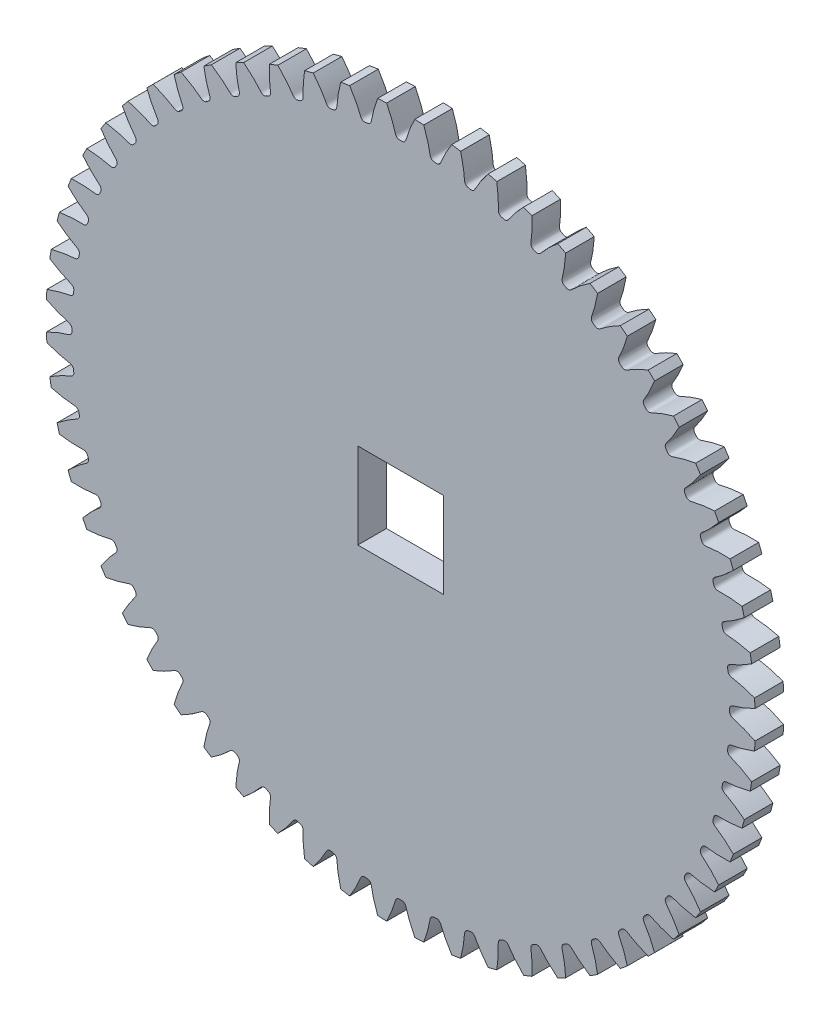
from build123d import *

# Parameters (mm, degrees)
SKETCHREVOLVEENGRANAJE_FINO_12_4_W       = 0.5
SKETCHREVOLVEENGRANAJE_FINO_12_4_H       = 6.2
TOOTHEXTRUDECUTENGRANAJE_FINO_12_4_DEPTH = 0.25
PATTERNENGRANAJE_FINO_12_4_COUNT         = 60
CROQUIS1_W                               = 1.5
CROQUIS1_H                               = 1.5
CORTAR_EXTRUIR1_DEPTH                    = 10


with BuildPart() as part:
    # SketchRevolveEngranaje Fino_12.4 → Engranaje Fino_12.4 (revolve)
    with BuildSketch(Plane(origin=(0, 0, 0), x_dir=(0, 0, -1), z_dir=(1, 0, 0))):
        with Locations((0, 3.1)):
            Rectangle(SKETCHREVOLVEENGRANAJE_FINO_12_4_W, SKETCHREVOLVEENGRANAJE_FINO_12_4_H)
    revolve(axis=Axis((0, 0, 0), (0, 0, -1)))

    # SketchToothEngranaje Fino_12.4 → ToothExtrudeCutEngranaje Fino_12.4 (cut, symmetric)
    with BuildSketch(Plane.XY):
        with BuildLine():
            ThreePointArc((6.204925678, 0.250992683), (6.21, 0), (6.204925678, -0.250992683))
            add(Edge.make_bspline(
                [(6.204925678, -0.250992683), (6.179966329, -0.238222226), (6.1468348, -0.221938109), (6.105502518, -0.202786997), (6.081860826, -0.19215202), (6.058747297, -0.18206364), (6.036171119, -0.172508696), (6.014141246, -0.163473877), (5.992666403, -0.154945749), (5.971755085, -0.146910734), (5.95141554, -0.139355173), (5.931655825, -0.132265126), (5.912483602, -0.125627101), (5.893906846, -0.119425486), (5.87593134, -0.113651649), (5.858569516, -0.108271809), (5.84014338, -0.10285013), (5.826164105, -0.098730913), (5.816332425, -0.096177961), (5.812269746, -0.094977221), (5.808251512, -0.093683063), (5.804262805, -0.092266595), (5.800281537, -0.090708909), (5.796283263, -0.088979434), (5.792239737, -0.087038528), (5.788119777, -0.084832402), (5.783890851, -0.082288663), (5.779523099, -0.079310151), (5.774997526, -0.075768255), (5.770321331, -0.071497671), (5.76555335, -0.066297996), (5.760841668, -0.059952869), (5.756459307, -0.052281293), (5.752833065, -0.04323286), (5.750494435, -0.033314639), (5.749578137, -0.018735376), (5.750293671, 0), (5.749578137, 0.018735376), (5.750494435, 0.033314639), (5.752833065, 0.04323286), (5.756459307, 0.052281293), (5.760841668, 0.059952869), (5.76555335, 0.066297996), (5.770321331, 0.071497671), (5.774997526, 0.075768255), (5.779523099, 0.079310151), (5.783890851, 0.082288663), (5.788119777, 0.084832402), (5.792239737, 0.087038528), (5.796283263, 0.088979434), (5.800281537, 0.090708909), (5.804262805, 0.092266595), (5.808251512, 0.093683063), (5.812269746, 0.094977221), (5.816332425, 0.096177961), (5.826164105, 0.098730913), (5.84014338, 0.10285013), (5.858569516, 0.108271809), (5.87593134, 0.113651649), (5.893906846, 0.119425486), (5.912483602, 0.125627101), (5.931655825, 0.132265126), (5.95141554, 0.139355173), (5.971755085, 0.146910734), (5.992666403, 0.154945749), (6.014141246, 0.163473877), (6.036171119, 0.172508696), (6.058747297, 0.18206364), (6.081860826, 0.19215202), (6.105502518, 0.202786997), (6.1468348, 0.221938109), (6.179966329, 0.238222226), (6.204925678, 0.250992683)],
                knots=[0, 0, 0, 0, 0.076643471, 0.100907917, 0.124530541, 0.147511341, 0.169850319, 0.191547473, 0.212602804, 0.233016312, 0.252787997, 0.271917859, 0.290405898, 0.308252114, 0.325456506, 0.342019076, 0.357939822, 0.377966124, 0.381853223, 0.38570675, 0.389545591, 0.393392716, 0.39727624, 0.401230769, 0.405299107, 0.409534341, 0.414002283, 0.418784036, 0.423978014, 0.429699889, 0.436077405, 0.443234951, 0.45126173, 0.460161641, 0.469798585, 0.478975881, 0.5, 0.521024119, 0.530201415, 0.539838359, 0.54873827, 0.556765049, 0.563922595, 0.570300111, 0.576021986, 0.581215964, 0.585997717, 0.590465659, 0.594700893, 0.598769231, 0.60272376, 0.606607284, 0.610454409, 0.61429325, 0.618146777, 0.622033876, 0.642060178, 0.657980924, 0.674543494, 0.691747886, 0.709594102, 0.728082141, 0.747212003, 0.766983688, 0.787397196, 0.808452527, 0.830149681, 0.852488659, 0.875469459, 0.899092083, 0.923356529, 1, 1, 1, 1], degree=3))
        make_face()
    toothextrudecutengranaje_fino_12_4 = extrude(amount=TOOTHEXTRUDECUTENGRANAJE_FINO_12_4_DEPTH, both=True, mode=Mode.SUBTRACT)

    # PatternEngranaje Fino_12.4: ToothExtrudeCutEngranaje Fino_12.4 ×60 about axis
    patternengranaje_fino_12_4_axis = Axis((0, 0, 0.275), (0, 0, -1))
    for i in range(1, PATTERNENGRANAJE_FINO_12_4_COUNT):
        add(toothextrudecutengranaje_fino_12_4.rotate(patternengranaje_fino_12_4_axis, i * 360 / PATTERNENGRANAJE_FINO_12_4_COUNT), mode=Mode.SUBTRACT)

    # Croquis1 → Cortar-Extruir1 (cut)
    with BuildSketch(Plane.XY.offset(0.25)):
        Rectangle(CROQUIS1_W, CROQUIS1_H)
    extrude(amount=-CORTAR_EXTRUIR1_DEPTH, mode=Mode.SUBTRACT)


solid = part.part
